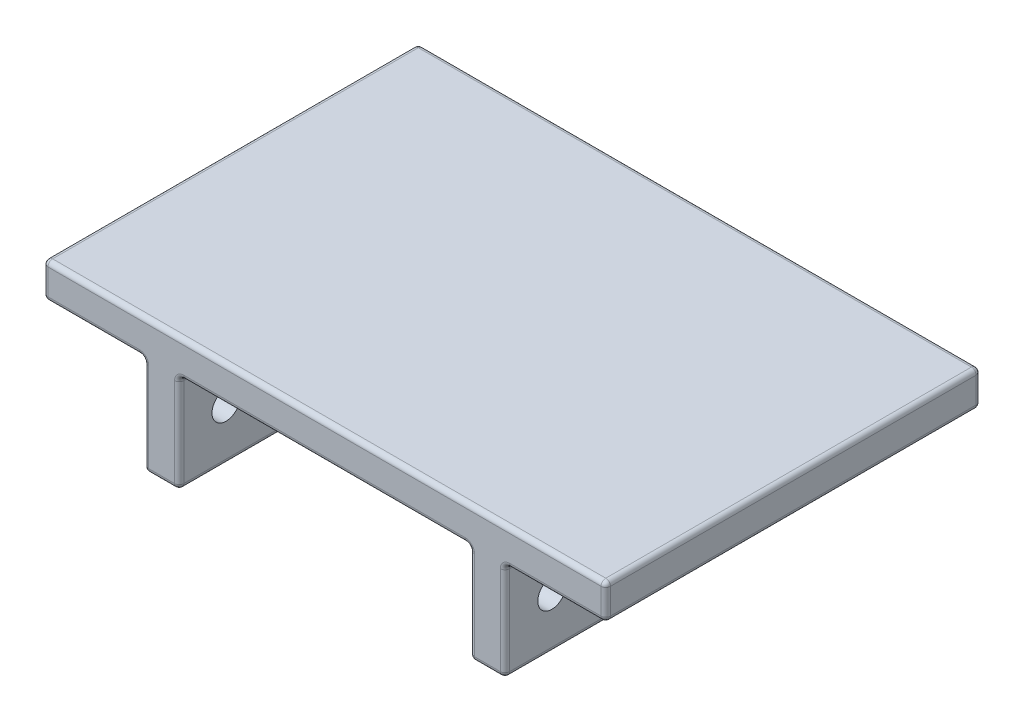
from build123d import *

# Parameters (mm, degrees)
SKETCH1_W           = 152.4
SKETCH1_H           = 101.6
BOSS_EXTRUDE1_DEPTH = 9.525
SKETCH2_W           = 9.525
SKETCH2_H           = 101.6
BOSS_EXTRUDE2_DEPTH = 26.67
FILLET1_R           = 1.27
SKETCH3_R           = 3.81
CUT_EXTRUDE1_DEPTH  = 126.095


with BuildPart() as part:
    # Sketch1 → Boss-Extrude1 (new body)
    with BuildSketch(Plane(origin=(0, 0, 0), x_dir=(1, 0, 0), z_dir=(0, 1, 0))):
        Rectangle(SKETCH1_W, SKETCH1_H)
    extrude(amount=-BOSS_EXTRUDE1_DEPTH)

    # Sketch2 → Boss-Extrude2 (add)
    with BuildSketch(Plane.XZ.offset(9.525)):
        with Locations((-44.1325, 0)):
            Rectangle(SKETCH2_W, SKETCH2_H)
        with Locations((44.1325, 0)):
            Rectangle(SKETCH2_W, SKETCH2_H)
    extrude(amount=BOSS_EXTRUDE2_DEPTH)

    # Fillet1
    fillet1_edges = [part.edges().sort_by_distance(p)[0] for p in [
        (-76.2, -9.525, 0),
        (0, -9.525, 50.8),
        (-62.5475, -9.525, -50.8),
        (-39.37, -36.195, 0),
        (-39.37, -22.86, -50.8),
        (-62.5475, -9.525, 50.8),
        (-39.37, -22.86, 50.8),
        (-48.895, -9.525, 0),
        (-48.895, -22.86, 50.8),
        (-48.895, -22.86, -50.8),
        (-44.1325, -36.195, 50.8),
        (-48.895, -36.195, 0),
        (-44.1325, -36.195, -50.8),
        (-39.37, -9.525, 0),
        (62.5475, -9.525, 50.8),
        (0, -9.525, -50.8),
        (48.895, -22.86, 50.8),
        (39.37, -9.525, 0),
        (39.37, -22.86, 50.8),
        (39.37, -22.86, -50.8),
        (48.895, -36.195, 0),
        (48.895, -22.86, -50.8),
        (44.1325, -36.195, 50.8),
        (39.37, -36.195, 0),
        (44.1325, -36.195, -50.8),
        (48.895, -9.525, 0),
        (76.2, -9.525, 0),
        (0, 0, 50.8),
        (-76.2, 0, 0),
        (0, 0, -50.8),
        (76.2, 0, 0),
        (76.2, -4.7625, 50.8),
        (-76.2, -4.7625, 50.8),
        (-76.2, -4.7625, -50.8),
        (76.2, -4.7625, -50.8),
        (62.5475, -9.525, -50.8),
    ]]
    fillet(fillet1_edges, radius=FILLET1_R)

    # Sketch3 → Cut-Extrude1 (cut, through all)
    with BuildSketch(Plane.ZY.offset(48.895)):
        with Locations((12.7, -22.225)):
            Circle(SKETCH3_R)
        with Locations((38.1, -22.225)):
            Circle(SKETCH3_R)
        with Locations((-38.1, -22.225)):
            Circle(SKETCH3_R)
        with Locations((-12.7, -22.225)):
            Circle(SKETCH3_R)
    extrude(amount=-CUT_EXTRUDE1_DEPTH, mode=Mode.SUBTRACT)


solid = part.part
